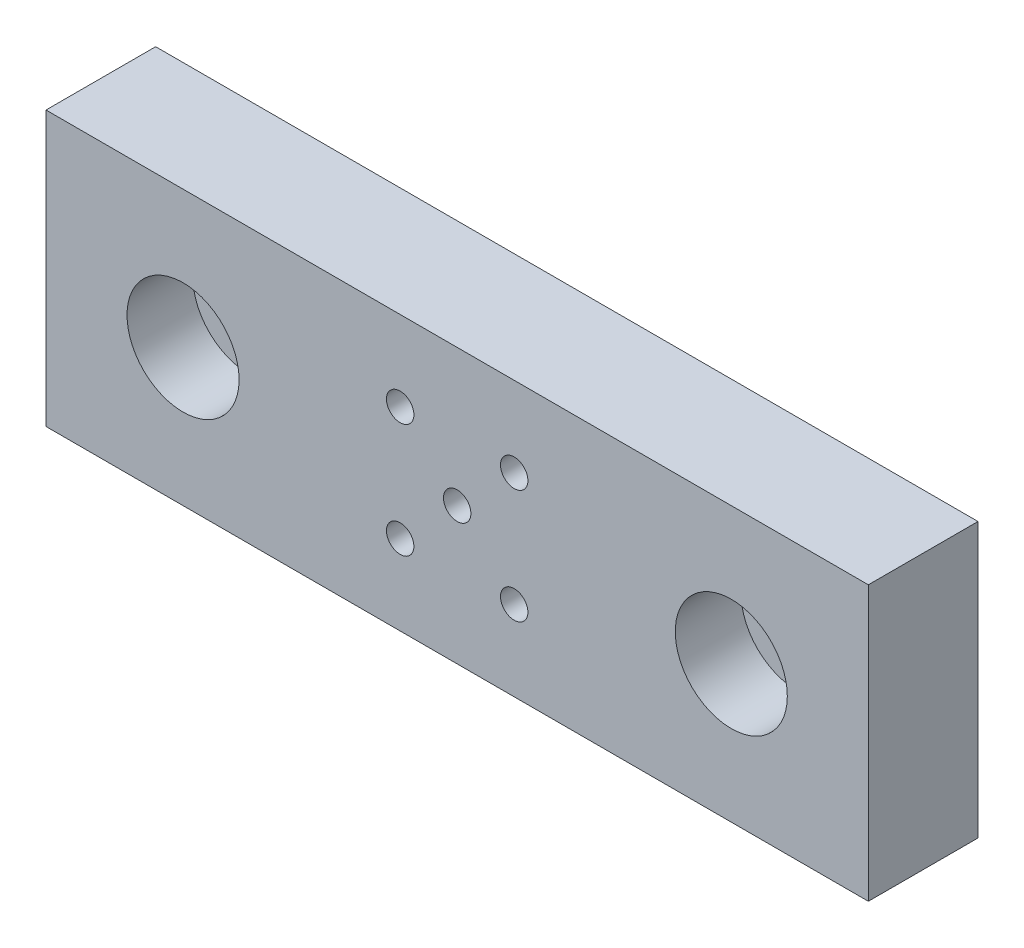
from build123d import *

# Parameters (mm, degrees)
SKETCH1_R           = 3.25
SKETCH1_R_2         = 1.25
BOSS_EXTRUDE1_DEPTH = 10
SKETCH2_R           = 5.11
CUT_EXTRUDE1_DEPTH  = 6


with BuildPart() as part:
    # Sketch1 → Boss-Extrude1 (new body)
    with BuildSketch(Plane.XY):
        Polygon((-37.5, 12.5), (37.5, 12.5), (37.5, 0), (37.5, -12.5), (-37.5, -12.5), (-37.5, 0), align=None)
        with Locations((-25, 0)):
            Circle(SKETCH1_R, mode=Mode.SUBTRACT)
        with Locations((25, 0)):
            Circle(SKETCH1_R, mode=Mode.SUBTRACT)
        Circle(SKETCH1_R_2, mode=Mode.SUBTRACT)
        with Locations((-5.2, 5.2)):
            Circle(SKETCH1_R_2, mode=Mode.SUBTRACT)
        with Locations((5.2, 5.2)):
            Circle(SKETCH1_R_2, mode=Mode.SUBTRACT)
        with Locations((5.2, -5.2)):
            Circle(SKETCH1_R_2, mode=Mode.SUBTRACT)
        with Locations((-5.2, -5.2)):
            Circle(SKETCH1_R_2, mode=Mode.SUBTRACT)
    extrude(amount=BOSS_EXTRUDE1_DEPTH)

    # Sketch2 → Cut-Extrude1 (cut)
    with BuildSketch(Plane.XY.offset(10)):
        with Locations((-25, 0)):
            Circle(SKETCH2_R)
        with Locations((25, 0)):
            Circle(SKETCH2_R)
    extrude(amount=-CUT_EXTRUDE1_DEPTH, mode=Mode.SUBTRACT)


solid = part.part
